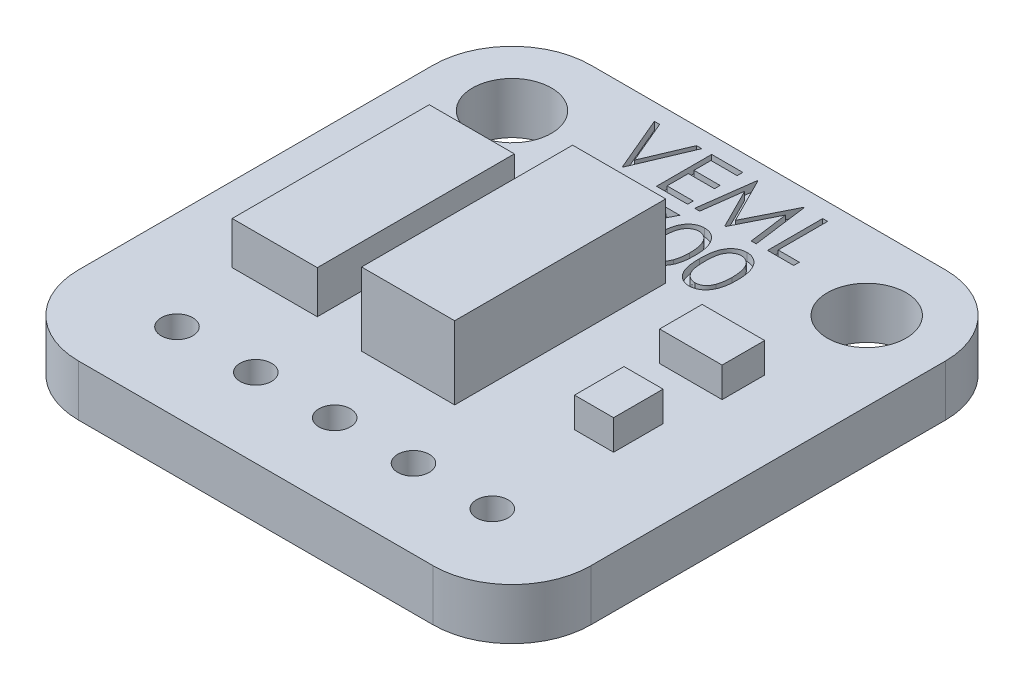
from build123d import *

# Parameters (mm, degrees)
SKETCH1_W             = 16.51
SKETCH1_H             = 16.51
BOSS_EXTRUDE1_DEPTH   = 1.651
SKETCH2_R             = 1.27
CUT_EXTRUDE1_DEPTH    = 2.651
FILLET1_R             = 2.54
SKETCH3_W             = 3
SKETCH3_H             = 6.8
BOSS_EXTRUDE2_DEPTH   = 2.35
SKETCH4_R             = 0.508
CUT_EXTRUDE2_DEPTH    = 2.651
LPATTERN1_COUNT       = 3
LPATTERN1_PITCH       = 2.54
LPATTERN1_COL_COUNT   = 3
LPATTERN1_COL_PITCH   = 2.54
CUT_EXTRUDE3_DEPTH    = 0.254
SKETCH6_W             = 2.7432
SKETCH6_H             = 6.35
BOSS_EXTRUDE3_DEPTH   = 1.3716
SKETCH6_W_2           = 2.014448681
SKETCH6_H_2           = 1.370944242
BOSS_EXTRUDE3_2_DEPTH = 1.3716
SKETCH6_W_3           = 1.259030426
SKETCH6_H_3           = 1.594771872
BOSS_EXTRUDE3_3_DEPTH = 1.3716
SKETCH7_W             = 3.357414469
SKETCH7_H             = 5.427820057
CUT_EXTRUDE4_DEPTH    = 0.4064
SKETCH8_W             = 2.548569118
SKETCH8_H             = 5.740755426
BOSS_EXTRUDE4_DEPTH   = 0.762
SKETCH9_W             = 0.762
SKETCH9_H             = 0.762
BOSS_EXTRUDE5_DEPTH   = 0.508


with BuildPart() as part:
    # Sketch1 → Boss-Extrude1 (new body)
    with BuildSketch(Plane(origin=(0, 0, 0), x_dir=(1, 0, 0), z_dir=(0, 1, 0))):
        Rectangle(SKETCH1_W, SKETCH1_H)
    extrude(amount=BOSS_EXTRUDE1_DEPTH)

    # Sketch2 → Cut-Extrude1 (cut, through all)
    with BuildSketch(Plane(origin=(0, 1.651, 0), x_dir=(1, 0, 0), z_dir=(0, 1, 0))):
        with Locations((-5.715, 5.715)):
            Circle(SKETCH2_R)
        with Locations((5.715, 5.715)):
            Circle(SKETCH2_R)
    extrude(amount=-CUT_EXTRUDE1_DEPTH, mode=Mode.SUBTRACT)

    # Fillet1
    fillet1_edges = [part.edges().sort_by_distance(p)[0] for p in [
        (8.255, 0.8255, 8.255),
        (-8.255, 0.8255, 8.255),
        (-8.255, 0.8255, -8.255),
        (8.255, 0.8255, -8.255),
    ]]
    fillet(fillet1_edges, radius=FILLET1_R)

    # Sketch4 → Cut-Extrude2 (cut, through all)
    with BuildSketch(Plane(origin=(0, 1.651, 0), x_dir=(1, 0, 0), z_dir=(0, 1, 0))):
        with Locations((0, -5.715)):
            Circle(SKETCH4_R)
    cut_extrude2 = extrude(amount=-CUT_EXTRUDE2_DEPTH, mode=Mode.SUBTRACT)

    # LPattern1: Cut-Extrude2 ×3
    with Locations(*[(i * LPATTERN1_PITCH, 0, 0) for i in range(1, LPATTERN1_COUNT)]):
        add(cut_extrude2, mode=Mode.SUBTRACT)

    # LPattern1 col: Cut-Extrude2 ×3
    with Locations(*[(-i * LPATTERN1_COL_PITCH, 0, 0) for i in range(1, LPATTERN1_COL_COUNT)]):
        add(cut_extrude2, mode=Mode.SUBTRACT)

    # Sketch5 → Cut-Extrude3 (cut)
    with BuildSketch(Plane(origin=(0, 1.651, 0), x_dir=(1, 0, 0), z_dir=(0, 1, 0))):
        Polygon((-3.122897436, 7.709835685), (-2.951935897, 7.709835685), (-2.359269231, 6.308663409), (-1.766602564, 7.709835685), (-1.595641026, 7.709835685), (-2.347871795, 5.931835685), (-2.370666667, 5.931835685), align=None)
        Polygon((-1.276512821, 7.709835685), (-0.273538462, 7.709835685), (-0.273538462, 7.52747671), (-1.116948718, 7.52747671), (-1.116948718, 6.980399787), (-0.273538462, 6.980399787), (-0.273538462, 6.798040813), (-1.116948718, 6.798040813), (-1.116948718, 6.114194659), (-0.273538462, 6.114194659), (-0.273538462, 5.931835685), (-1.276512821, 5.931835685), align=None)
        Polygon((-0.045589744, 5.931835685), (0.189126202, 7.709835685), (0.211921074, 7.709835685), (0.945987179, 6.25096389), (1.678272436, 7.709835685), (1.701423478, 7.709835685), (1.937564103, 5.931835685), (1.77728766, 5.931835685), (1.607038462, 7.211197864), (0.965220353, 5.931835685), (0.929247196, 5.931835685), (0.284935897, 7.214047223), (0.115042869, 5.931835685), align=None)
        Polygon((2.302282051, 7.709835685), (2.461846154, 7.709835685), (2.461846154, 6.114194659), (3.145692308, 6.114194659), (3.145692308, 5.931835685), (2.302282051, 5.931835685), align=None)
        Polygon((-2.553025641, 5.498301957), (-1.458871795, 5.498301957), (-2.393461538, 3.674712213), (-2.531299279, 3.750576396), (-1.728848558, 5.315942983), (-2.553025641, 5.315942983), align=None)
        Polygon((-1.185333333, 5.498301957), (-0.091179487, 5.498301957), (-1.025769231, 3.674712213), (-1.163606971, 3.750576396), (-0.36115625, 5.315942983), (-1.185333333, 5.315942983), align=None)
        with BuildLine():
            add(Edge.make_bspline(
                [(0.068384615, 4.608589617), (0.068551249, 4.63708709), (0.068874936, 4.692443842), (0.072475854, 4.77310644), (0.078457728, 4.848778267), (0.086655513, 4.919462945), (0.096631607, 4.985178721), (0.109949074, 5.045749978), (0.125093978, 5.101457058), (0.142646621, 5.152481618), (0.162452417, 5.199511092), (0.184009022, 5.243415094), (0.208171937, 5.284127196), (0.233560209, 5.322297193), (0.261201542, 5.35730027), (0.290309327, 5.389630743), (0.32201964, 5.418541404), (0.355254528, 5.444879325), (0.390314892, 5.467967657), (0.426201367, 5.488304288), (0.463160961, 5.505677821), (0.501294581, 5.519338162), (0.540259481, 5.530621272), (0.580191871, 5.538337258), (0.621157684, 5.543192167), (0.648808852, 5.543656311), (0.662832131, 5.543891701)],
                knots=[0, 0, 0, 0, 8.5487e-05, 0.000166061, 0.000242166, 0.000313162, 0.000379506, 0.000441472, 0.000499107, 0.00055261, 0.000603213, 0.000652114, 0.000699211, 0.000745145, 0.000789535, 0.0008329, 0.0008755, 0.000918109, 0.000959994, 0.0010013, 0.001041774, 0.001082336, 0.001122698, 0.001163352, 0.001204218, 0.00124627, 0.00124627, 0.00124627, 0.00124627], degree=3))
            add(Edge.make_bspline(
                [(0.662832131, 5.543891701), (0.676972554, 5.54364389), (0.705093407, 5.543151074), (0.746668318, 5.538414511), (0.787282756, 5.530555181), (0.82676357, 5.519419326), (0.865435064, 5.505603922), (0.902994759, 5.488287666), (0.939675956, 5.468130802), (0.974895742, 5.444445872), (1.009040767, 5.418038876), (1.041272332, 5.38818744), (1.071593372, 5.355192983), (1.100384427, 5.319408516), (1.12682867, 5.280147693), (1.152011974, 5.238093365), (1.174552968, 5.192510086), (1.196262183, 5.144158408), (1.215000772, 5.091700469), (1.231900025, 5.035431971), (1.245554541, 4.974688284), (1.256928291, 4.909788111), (1.265739498, 4.84049311), (1.27215688, 4.766951822), (1.275546808, 4.689115863), (1.276185212, 4.635898876), (1.276512821, 4.608589617)],
                knots=[0, 0, 0, 0, 4.2408e-05, 8.4336e-05, 0.000125339, 0.000166387, 0.000207285, 0.000248405, 0.000290333, 0.000332711, 0.000375601, 0.00041971, 0.000464323, 0.000509935, 0.000557354, 0.00060622, 0.000656873, 0.000709816, 0.000765138, 0.000823849, 0.000885971, 0.000951789, 0.001021457, 0.001095462, 0.001173189, 0.00125512, 0.00125512, 0.00125512, 0.00125512], degree=3))
            add(Edge.make_bspline(
                [(1.276512821, 4.608589617), (1.276181816, 4.581399472), (1.275536866, 4.528420583), (1.272194883, 4.450934847), (1.265611898, 4.377783841), (1.257377224, 4.308792126), (1.245972135, 4.244246856), (1.231948711, 4.183924676), (1.216378347, 4.127565088), (1.197158271, 4.075629804), (1.17612163, 4.027394328), (1.153233591, 3.982351417), (1.128712519, 3.94010294), (1.101997437, 3.900987069), (1.073522303, 3.864726711), (1.042677666, 3.831961919), (1.010333009, 3.801903217), (0.976087501, 3.775156191), (0.940318433, 3.75174511), (0.903763222, 3.730808474), (0.865773264, 3.713926265), (0.827209484, 3.699430464), (0.787520274, 3.688355834), (0.746755107, 3.680698316), (0.705121339, 3.675327817), (0.676977344, 3.674918125), (0.662832131, 3.674712213)],
                knots=[0, 0, 0, 0, 8.1575e-05, 0.000158946, 0.000232597, 0.000301867, 0.000367334, 0.000429108, 0.000487621, 0.000542607, 0.000595082, 0.000645417, 0.000694102, 0.000741521, 0.000787412, 0.000832267, 0.000876376, 0.000919766, 0.000962441, 0.001004543, 0.001045987, 0.001087007, 0.001128055, 0.001169407, 0.001211376, 0.001253784, 0.001253784, 0.001253784, 0.001253784], degree=3))
            add(Edge.make_bspline(
                [(0.662832131, 3.674712213), (0.648809242, 3.674949122), (0.62115884, 3.675416259), (0.580187408, 3.680249235), (0.540419926, 3.688019351), (0.501660159, 3.698898986), (0.46370925, 3.712216122), (0.427084336, 3.729566194), (0.391378193, 3.749547901), (0.356686082, 3.772303975), (0.323659904, 3.79837539), (0.292113813, 3.827211648), (0.262840303, 3.859532341), (0.235594183, 3.894827126), (0.209699346, 3.932771293), (0.185879544, 3.973882907), (0.16384715, 4.017998953), (0.143708257, 4.065404452), (0.125852736, 4.116791155), (0.1100805, 4.172746938), (0.097627308, 4.233765681), (0.086967967, 4.299357303), (0.07837038, 4.36980366), (0.072500783, 4.445142995), (0.068872995, 4.525328361), (0.068550379, 4.580329407), (0.068384615, 4.608589617)],
                knots=[0, 0, 0, 0, 4.2052e-05, 8.2919e-05, 0.000123572, 0.000163495, 0.000203602, 0.000244075, 0.000284897, 0.000326287, 0.000368397, 0.000410996, 0.000454361, 0.000499032, 0.000544671, 0.000592075, 0.000641454, 0.000692524, 0.00074648, 0.000804553, 0.000866793, 0.000933194, 0.001003878, 0.001079628, 0.001159846, 0.001244621, 0.001244621, 0.001244621, 0.001244621], degree=3))
        make_face()
        with BuildLine():
            add(Edge.make_bspline(
                [(0.227948718, 4.609301957), (0.228009397, 4.585553618), (0.228127163, 4.539462755), (0.231203713, 4.472486379), (0.235394831, 4.410017452), (0.24080061, 4.351976655), (0.248828508, 4.298560449), (0.257823556, 4.24940145), (0.268769986, 4.204759813), (0.281721455, 4.164329205), (0.296473316, 4.127423479), (0.312579895, 4.093082061), (0.329882742, 4.060899278), (0.34924727, 4.031164205), (0.370336922, 4.003779873), (0.392675338, 3.978261594), (0.417096211, 3.955504728), (0.450880112, 3.928211486), (0.495480721, 3.900007766), (0.551675912, 3.875447952), (0.609419485, 3.860013664), (0.648612321, 3.858050876), (0.668174679, 3.857071188)],
                knots=[0, 0, 0, 0, 7.1238e-05, 0.000138258, 0.00020109, 0.00025907, 0.000313067, 0.000363083, 0.000408953, 0.000450854, 0.000490339, 0.000528101, 0.0005646, 0.000599868, 0.000634418, 0.000668226, 0.000701486, 0.000734415, 0.000798447, 0.000859058, 0.000917887, 0.000976511, 0.000976511, 0.000976511, 0.000976511], degree=3))
            add(Edge.make_bspline(
                [(0.668174679, 3.857071188), (0.687863577, 3.85788286), (0.727200721, 3.85950453), (0.784672689, 3.875150288), (0.840466466, 3.898756815), (0.884191012, 3.926670147), (0.917456144, 3.953252939), (0.941289975, 3.97591718), (0.963165495, 4.001294761), (0.983913269, 4.028675603), (1.00294248, 4.058582825), (1.020246554, 4.090872613), (1.036036894, 4.125634635), (1.04503309, 4.149901663), (1.049632612, 4.162308768)],
                knots=[0, 0, 0, 0, 5.895e-05, 0.000117779, 0.000177454, 0.000240201, 0.00027263, 0.000305128, 0.000338701, 0.000373035, 0.00040811, 0.000444922, 0.000482859, 0.000522546, 0.000522546, 0.000522546, 0.000522546], degree=3))
            add(Edge.make_bspline(
                [(1.049632612, 4.162308768), (1.05499291, 4.178173476), (1.065876614, 4.210385636), (1.079903395, 4.260354371), (1.090950058, 4.312781375), (1.100888248, 4.367353334), (1.1076716, 4.424472702), (1.11313149, 4.483962746), (1.116347478, 4.545868318), (1.116746132, 4.587928173), (1.116948718, 4.609301957)],
                knots=[0, 0, 0, 0, 5.0234e-05, 0.000101996, 0.000155579, 0.000210915, 0.000268346, 0.000328066, 0.000390122, 0.000454242, 0.000454242, 0.000454242, 0.000454242], degree=3))
            add(Edge.make_bspline(
                [(1.116948718, 4.609301957), (1.116669222, 4.630672284), (1.116122468, 4.672477212), (1.114032562, 4.733700447), (1.108635786, 4.79185007), (1.102641834, 4.84717659), (1.093804045, 4.899373744), (1.084275079, 4.948878499), (1.071472864, 4.995077555), (1.057797618, 5.038694223), (1.042145937, 5.079232955), (1.024916744, 5.116882759), (1.006516091, 5.151825399), (0.986530232, 5.183965005), (0.965196425, 5.213445537), (0.94195159, 5.239675911), (0.917717769, 5.263469091), (0.883774639, 5.290628076), (0.839337699, 5.318320017), (0.784044111, 5.343804223), (0.726502623, 5.358438836), (0.687603309, 5.360502173), (0.668174679, 5.361532726)],
                knots=[0, 0, 0, 0, 6.4119e-05, 0.000125431, 0.000183701, 0.000239278, 0.000292328, 0.000342481, 0.000390432, 0.000436051, 0.000479574, 0.000520694, 0.000560208, 0.000597962, 0.000634152, 0.000669232, 0.000702984, 0.000735913, 0.000799454, 0.000859558, 0.000917953, 0.000976223, 0.000976223, 0.000976223, 0.000976223], degree=3))
            add(Edge.make_bspline(
                [(0.668174679, 5.361532726), (0.648509699, 5.360500751), (0.609143912, 5.358434921), (0.551004351, 5.343858749), (0.495274541, 5.318452162), (0.450955109, 5.290536357), (0.416988306, 5.263948495), (0.393070298, 5.240892176), (0.370644042, 5.215671879), (0.349984851, 5.188035706), (0.330635495, 5.158335299), (0.31286514, 5.126337007), (0.296854337, 5.091878674), (0.282079392, 5.054989525), (0.269088416, 5.014562405), (0.258372683, 4.969975756), (0.24847326, 4.920973115), (0.241465263, 4.867267605), (0.235235275, 4.809212271), (0.231231551, 4.746587393), (0.228116872, 4.679498688), (0.228005892, 4.633169516), (0.227948718, 4.609301957)],
                knots=[0, 0, 0, 0, 5.8979e-05, 0.000118066, 0.000178495, 0.000242035, 0.000274743, 0.000307744, 0.000341552, 0.000375887, 0.000411155, 0.000447825, 0.000485587, 0.000525072, 0.000566973, 0.000612843, 0.000662577, 0.000716876, 0.000775247, 0.000837723, 0.000905099, 0.000976693, 0.000976693, 0.000976693, 0.000976693], degree=3))
        make_face(mode=Mode.SUBTRACT)
        with BuildLine():
            add(Edge.make_bspline(
                [(1.436076923, 4.608589617), (1.436243556, 4.63708709), (1.436567244, 4.692443842), (1.440168162, 4.77310644), (1.446150035, 4.848778267), (1.454347821, 4.919462945), (1.464323915, 4.985178721), (1.477641382, 5.045749978), (1.492786286, 5.101457058), (1.510338928, 5.152481618), (1.530144725, 5.199511092), (1.551701329, 5.243415094), (1.575864245, 5.284127196), (1.601252517, 5.322297193), (1.628893849, 5.35730027), (1.658001635, 5.389630743), (1.689711948, 5.418541404), (1.722946836, 5.444879325), (1.7580072, 5.467967657), (1.793893674, 5.488304288), (1.830853268, 5.505677821), (1.868986889, 5.519338162), (1.907951789, 5.530621272), (1.947884178, 5.538337258), (1.988849991, 5.543192167), (2.01650116, 5.543656311), (2.030524439, 5.543891701)],
                knots=[0, 0, 0, 0, 8.5487e-05, 0.000166061, 0.000242166, 0.000313162, 0.000379506, 0.000441472, 0.000499107, 0.00055261, 0.000603213, 0.000652114, 0.000699211, 0.000745145, 0.000789535, 0.0008329, 0.0008755, 0.000918109, 0.000959994, 0.0010013, 0.001041774, 0.001082336, 0.001122698, 0.001163352, 0.001204218, 0.00124627, 0.00124627, 0.00124627, 0.00124627], degree=3))
            add(Edge.make_bspline(
                [(2.030524439, 5.543891701), (2.044664862, 5.54364389), (2.072785715, 5.543151074), (2.114360625, 5.538414511), (2.154975064, 5.530555181), (2.194455878, 5.519419326), (2.233127371, 5.505603922), (2.270687066, 5.488287666), (2.307368264, 5.468130802), (2.34258805, 5.444445872), (2.376733074, 5.418038876), (2.40896464, 5.38818744), (2.439285679, 5.355192983), (2.468076734, 5.319408516), (2.494520978, 5.280147693), (2.519704281, 5.238093365), (2.542245276, 5.192510086), (2.563954491, 5.144158408), (2.58269308, 5.091700469), (2.599592332, 5.035431971), (2.613246848, 4.974688284), (2.624620599, 4.909788111), (2.633431806, 4.84049311), (2.639849188, 4.766951822), (2.643239115, 4.689115863), (2.64387752, 4.635898876), (2.644205128, 4.608589617)],
                knots=[0, 0, 0, 0, 4.2408e-05, 8.4336e-05, 0.000125339, 0.000166387, 0.000207285, 0.000248405, 0.000290333, 0.000332711, 0.000375601, 0.00041971, 0.000464323, 0.000509935, 0.000557354, 0.00060622, 0.000656873, 0.000709816, 0.000765138, 0.000823849, 0.000885971, 0.000951789, 0.001021457, 0.001095462, 0.001173189, 0.00125512, 0.00125512, 0.00125512, 0.00125512], degree=3))
            add(Edge.make_bspline(
                [(2.644205128, 4.608589617), (2.643874123, 4.581399472), (2.643229174, 4.528420583), (2.639887191, 4.450934847), (2.633304206, 4.377783841), (2.625069532, 4.308792126), (2.613664443, 4.244246856), (2.599641018, 4.183924676), (2.584070654, 4.127565088), (2.564850579, 4.075629804), (2.543813938, 4.027394328), (2.520925898, 3.982351417), (2.496404827, 3.94010294), (2.469689744, 3.900987069), (2.44121461, 3.864726711), (2.410369974, 3.831961919), (2.378025316, 3.801903217), (2.343779809, 3.775156191), (2.308010741, 3.75174511), (2.27145553, 3.730808474), (2.233465571, 3.713926265), (2.194901791, 3.699430464), (2.155212581, 3.688355834), (2.114447415, 3.680698316), (2.072813647, 3.675327817), (2.044669652, 3.674918125), (2.030524439, 3.674712213)],
                knots=[0, 0, 0, 0, 8.1575e-05, 0.000158946, 0.000232597, 0.000301867, 0.000367334, 0.000429108, 0.000487621, 0.000542607, 0.000595082, 0.000645417, 0.000694102, 0.000741521, 0.000787412, 0.000832267, 0.000876376, 0.000919766, 0.000962441, 0.001004543, 0.001045987, 0.001087007, 0.001128055, 0.001169407, 0.001211376, 0.001253784, 0.001253784, 0.001253784, 0.001253784], degree=3))
            add(Edge.make_bspline(
                [(2.030524439, 3.674712213), (2.016501549, 3.674949122), (1.988851147, 3.675416259), (1.947879715, 3.680249235), (1.908112234, 3.688019351), (1.869352467, 3.698898986), (1.831401557, 3.712216122), (1.794776644, 3.729566194), (1.7590705, 3.749547901), (1.72437839, 3.772303975), (1.691352212, 3.79837539), (1.659806121, 3.827211648), (1.630532611, 3.859532341), (1.60328649, 3.894827126), (1.577391654, 3.932771293), (1.553571852, 3.973882907), (1.531539458, 4.017998953), (1.511400565, 4.065404452), (1.493545044, 4.116791155), (1.477772808, 4.172746938), (1.465319616, 4.233765681), (1.454660275, 4.299357303), (1.446062688, 4.36980366), (1.440193091, 4.445142995), (1.436565303, 4.525328361), (1.436242687, 4.580329407), (1.436076923, 4.608589617)],
                knots=[0, 0, 0, 0, 4.2052e-05, 8.2919e-05, 0.000123572, 0.000163495, 0.000203602, 0.000244075, 0.000284897, 0.000326287, 0.000368397, 0.000410996, 0.000454361, 0.000499032, 0.000544671, 0.000592075, 0.000641454, 0.000692524, 0.00074648, 0.000804553, 0.000866793, 0.000933194, 0.001003878, 0.001079628, 0.001159846, 0.001244621, 0.001244621, 0.001244621, 0.001244621], degree=3))
        make_face()
        with BuildLine():
            add(Edge.make_bspline(
                [(1.595641026, 4.609301957), (1.595701705, 4.585553618), (1.595819471, 4.539462755), (1.598896021, 4.472486379), (1.603087139, 4.410017452), (1.608492918, 4.351976655), (1.616520816, 4.298560449), (1.625515864, 4.24940145), (1.636462293, 4.204759813), (1.649413762, 4.164329205), (1.664165624, 4.127423479), (1.680272202, 4.093082061), (1.69757505, 4.060899278), (1.716939578, 4.031164205), (1.73802923, 4.003779873), (1.760367646, 3.978261594), (1.784788519, 3.955504728), (1.81857242, 3.928211486), (1.863173029, 3.900007766), (1.91936822, 3.875447952), (1.977111793, 3.860013664), (2.016304628, 3.858050876), (2.035866987, 3.857071188)],
                knots=[0, 0, 0, 0, 7.1238e-05, 0.000138258, 0.00020109, 0.00025907, 0.000313067, 0.000363083, 0.000408953, 0.000450854, 0.000490339, 0.000528101, 0.0005646, 0.000599868, 0.000634418, 0.000668226, 0.000701486, 0.000734415, 0.000798447, 0.000859058, 0.000917887, 0.000976511, 0.000976511, 0.000976511, 0.000976511], degree=3))
            add(Edge.make_bspline(
                [(2.035866987, 3.857071188), (2.055555884, 3.85788286), (2.094893029, 3.85950453), (2.152364996, 3.875150288), (2.208158774, 3.898756815), (2.251883319, 3.926670147), (2.285148451, 3.953252939), (2.308982282, 3.97591718), (2.330857803, 4.001294761), (2.351605577, 4.028675603), (2.370634788, 4.058582825), (2.387938861, 4.090872613), (2.403729202, 4.125634635), (2.412725397, 4.149901663), (2.41732492, 4.162308768)],
                knots=[0, 0, 0, 0, 5.895e-05, 0.000117779, 0.000177454, 0.000240201, 0.00027263, 0.000305128, 0.000338701, 0.000373035, 0.00040811, 0.000444922, 0.000482859, 0.000522546, 0.000522546, 0.000522546, 0.000522546], degree=3))
            add(Edge.make_bspline(
                [(2.41732492, 4.162308768), (2.422685218, 4.178173476), (2.433568922, 4.210385636), (2.447595703, 4.260354371), (2.458642366, 4.312781375), (2.468580556, 4.367353334), (2.475363908, 4.424472702), (2.480823797, 4.483962746), (2.484039786, 4.545868318), (2.48443844, 4.587928173), (2.484641026, 4.609301957)],
                knots=[0, 0, 0, 0, 5.0234e-05, 0.000101996, 0.000155579, 0.000210915, 0.000268346, 0.000328066, 0.000390122, 0.000454242, 0.000454242, 0.000454242, 0.000454242], degree=3))
            add(Edge.make_bspline(
                [(2.484641026, 4.609301957), (2.48436153, 4.630672284), (2.483814775, 4.672477212), (2.48172487, 4.733700447), (2.476328094, 4.79185007), (2.470334141, 4.84717659), (2.461496353, 4.899373744), (2.451967387, 4.948878499), (2.439165171, 4.995077555), (2.425489926, 5.038694223), (2.409838245, 5.079232955), (2.392609052, 5.116882759), (2.374208398, 5.151825399), (2.35422254, 5.183965005), (2.332888733, 5.213445537), (2.309643898, 5.239675911), (2.285410077, 5.263469091), (2.251466946, 5.290628076), (2.207030007, 5.318320017), (2.151736418, 5.343804223), (2.094194931, 5.358438836), (2.055295616, 5.360502173), (2.035866987, 5.361532726)],
                knots=[0, 0, 0, 0, 6.4119e-05, 0.000125431, 0.000183701, 0.000239278, 0.000292328, 0.000342481, 0.000390432, 0.000436051, 0.000479574, 0.000520694, 0.000560208, 0.000597962, 0.000634152, 0.000669232, 0.000702984, 0.000735913, 0.000799454, 0.000859558, 0.000917953, 0.000976223, 0.000976223, 0.000976223, 0.000976223], degree=3))
            add(Edge.make_bspline(
                [(2.035866987, 5.361532726), (2.016202006, 5.360500751), (1.97683622, 5.358434921), (1.918696659, 5.343858749), (1.862966848, 5.318452162), (1.818647417, 5.290536357), (1.784680614, 5.263948495), (1.760762605, 5.240892176), (1.73833635, 5.215671879), (1.717677158, 5.188035706), (1.698327802, 5.158335299), (1.680557448, 5.126337007), (1.664546645, 5.091878674), (1.6497717, 5.054989525), (1.636780724, 5.014562405), (1.62606499, 4.969975756), (1.616165568, 4.920973115), (1.609157571, 4.867267605), (1.602927583, 4.809212271), (1.598923858, 4.746587393), (1.595809179, 4.679498688), (1.5956982, 4.633169516), (1.595641026, 4.609301957)],
                knots=[0, 0, 0, 0, 5.8979e-05, 0.000118066, 0.000178495, 0.000242035, 0.000274743, 0.000307744, 0.000341552, 0.000375887, 0.000411155, 0.000447825, 0.000485587, 0.000525072, 0.000566973, 0.000612843, 0.000662577, 0.000716876, 0.000775247, 0.000837723, 0.000905099, 0.000976693, 0.000976693, 0.000976693, 0.000976693], degree=3))
        make_face(mode=Mode.SUBTRACT)
    extrude(amount=-CUT_EXTRUDE3_DEPTH, mode=Mode.SUBTRACT)


with BuildPart() as body_2:
    # Sketch3 → Boss-Extrude2 (new body)
    with BuildSketch(Plane(origin=(0, 1.651, 0), x_dir=(1, 0, 0), z_dir=(0, 1, 0))):
        with Locations((0.0748, -0.0218)):
            Rectangle(SKETCH3_W, SKETCH3_H)
    extrude(amount=BOSS_EXTRUDE2_DEPTH)


with BuildPart() as body_3:
    # Sketch6 → Boss-Extrude3 (new body)
    with BuildSketch(Plane(origin=(0, 1.651, 0), x_dir=(1, 0, 0), z_dir=(0, 1, 0))):
        with Locations((-4.4704, 0)):
            Rectangle(SKETCH6_W, SKETCH6_H)
    extrude(amount=BOSS_EXTRUDE3_DEPTH)


with BuildPart() as body_4:
    # Sketch6 → Boss-Extrude3 2 (new body)
    with BuildSketch(Plane(origin=(0, 1.651, 0), x_dir=(1, 0, 0), z_dir=(0, 1, 0))):
        with Locations((4.72835871, 1.720674915)):
            Rectangle(SKETCH6_W_2, SKETCH6_H_2)
    extrude(amount=BOSS_EXTRUDE3_2_DEPTH)


with BuildPart() as body_5:
    # Sketch6 → Boss-Extrude3 3 (new body)
    with BuildSketch(Plane(origin=(0, 1.651, 0), x_dir=(1, 0, 0), z_dir=(0, 1, 0))):
        with Locations((4.826283298, -1.384933468)):
            Rectangle(SKETCH6_W_3, SKETCH6_H_3)
    extrude(amount=BOSS_EXTRUDE3_3_DEPTH)


with BuildPart() as cut_extrude4_tool:
    # Sketch7 → Cut-Extrude4 (new body)
    with BuildSketch(Plane(origin=(0, 3.0226, 0), x_dir=(1, 0, 0), z_dir=(0, 1, 0))):
        with Locations((4.812294072, 0.083935361)):
            Rectangle(SKETCH7_W, SKETCH7_H)
    extrude(amount=-CUT_EXTRUDE4_DEPTH)


with BuildPart() as body_4_1:
    add(body_4.part)

    # Cut-Extrude4: cut by cut_extrude4_tool
    add(cut_extrude4_tool.part, mode=Mode.SUBTRACT)


with BuildPart() as body_5_1:
    add(body_5.part)

    # Cut-Extrude4: cut by cut_extrude4_tool
    add(cut_extrude4_tool.part, mode=Mode.SUBTRACT)


with BuildPart() as body_6:
    # Sketch8 → Boss-Extrude4 (new body)
    with BuildSketch(Plane(origin=(0, 1.651, 0), x_dir=(1, 0, 0), z_dir=(0, 1, 0))):
        Rectangle(SKETCH8_W, SKETCH8_H)
    extrude(amount=BOSS_EXTRUDE4_DEPTH)


with BuildPart() as body_7:
    # Sketch9 → Boss-Extrude5 (new body)
    with BuildSketch(Plane(origin=(0, 2.413, 0), x_dir=(1, 0, 0), z_dir=(0, 1, 0))):
        with Locations((0.639284559, 0)):
            Rectangle(SKETCH9_W, SKETCH9_H)
    extrude(amount=BOSS_EXTRUDE5_DEPTH)


solid = Compound([part.part, body_2.part, body_3.part, body_4_1.part, body_5_1.part, body_6.part, body_7.part])
